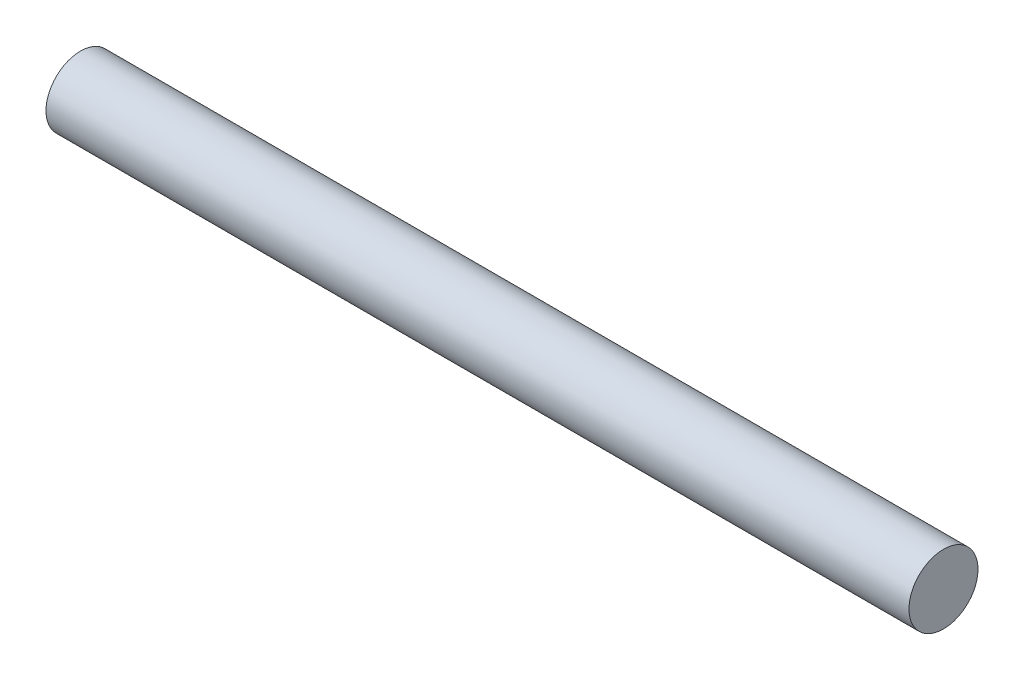
from build123d import *

# Parameters (mm, degrees)
SKETCH1_W = 100
SKETCH1_H = 4


with BuildPart() as part:
    # Sketch1 → Revolve1 (revolve)
    with BuildSketch(Plane.XY):
        with Locations((0, 2)):
            Rectangle(SKETCH1_W, SKETCH1_H)
    revolve(axis=Axis((50, 0, 0), (-1, 0, 0)))


solid = part.part
